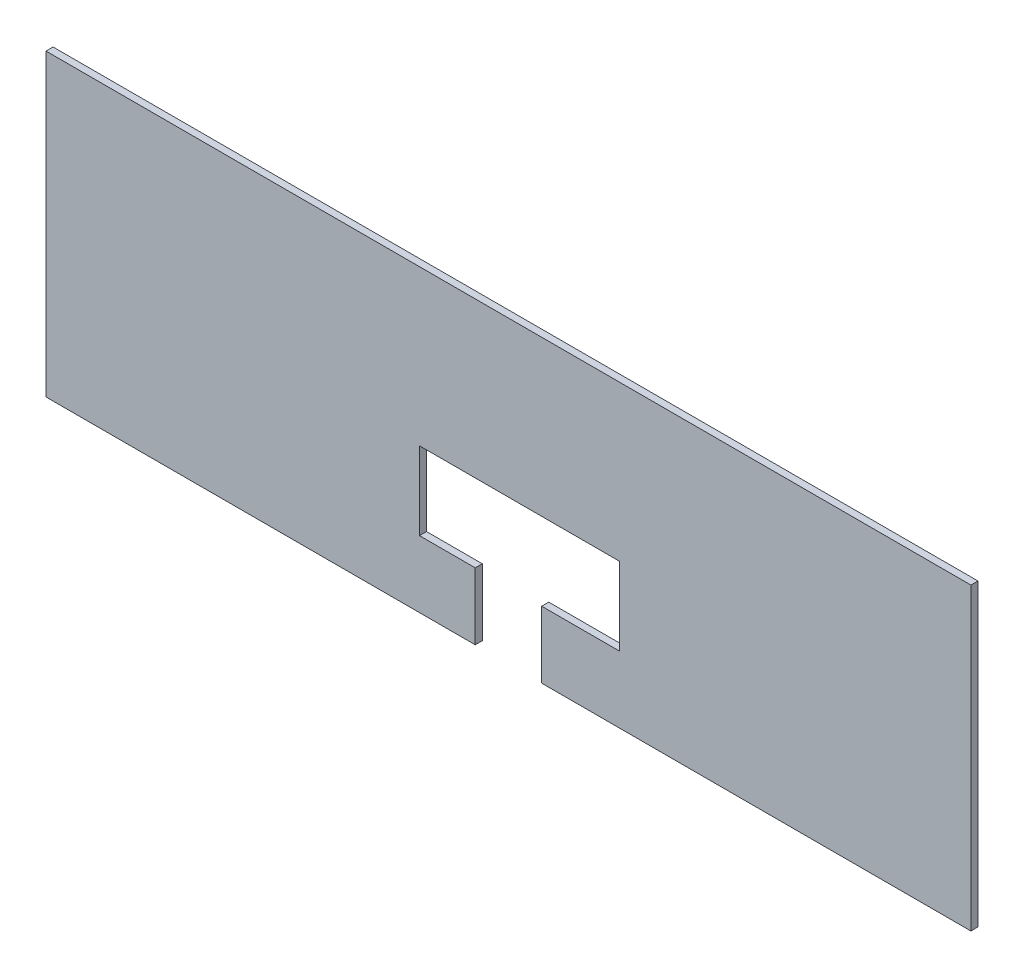
from build123d import *

# Parameters (mm, degrees)
BOSS_EXTRUDE1_DEPTH = 3.175


with BuildPart() as part:
    # Sketch1 → Boss-Extrude1 (new body)
    with BuildSketch(Plane.XY):
        Polygon((-368.442877504, 111.148523924), (47.637122496, 111.148523924), (47.637122496, -23.626476076), (-145.452877504, -23.626476076), (-145.452877504, 6.373523924), (-110.452877504, 6.373523924), (-110.452877504, 41.373523924), (-200.433646142, 41.373523924), (-200.433646142, 6.373523924), (-175.352877504, 6.373523924), (-175.352877504, -23.626476076), (-368.442877504, -23.626476076), align=None)
    extrude(amount=BOSS_EXTRUDE1_DEPTH)


solid = part.part
